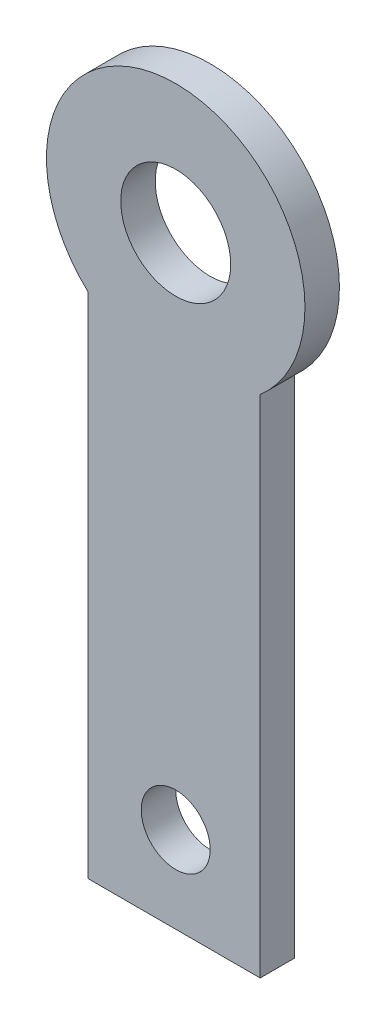
from build123d import *

# Parameters (mm, degrees)
SKETCH1_R           = 1.595
SKETCH1_R_2         = 1
BOSS_EXTRUDE1_DEPTH = 1


with BuildPart() as part:
    # Sketch1 → Boss-Extrude1 (new body)
    with BuildSketch(Plane.XY):
        with BuildLine():
            Line((12.950297731, 5.25017849), (12.950297731, -9.5))
            Line((12.950297731, -9.5), (17.950297731, -9.5))
            Line((17.950297731, -9.5), (17.950297731, 5.161243048))
            ThreePointArc((17.950297731, 5.161243048), (15.566691032, 11.749406927), (12.950297731, 5.25017849))
        make_face()
        with Locations((15.5, 8)):
            Circle(SKETCH1_R, mode=Mode.SUBTRACT)
        with Locations((15.5, -7)):
            Circle(SKETCH1_R_2, mode=Mode.SUBTRACT)
    extrude(amount=BOSS_EXTRUDE1_DEPTH)


solid = part.part
